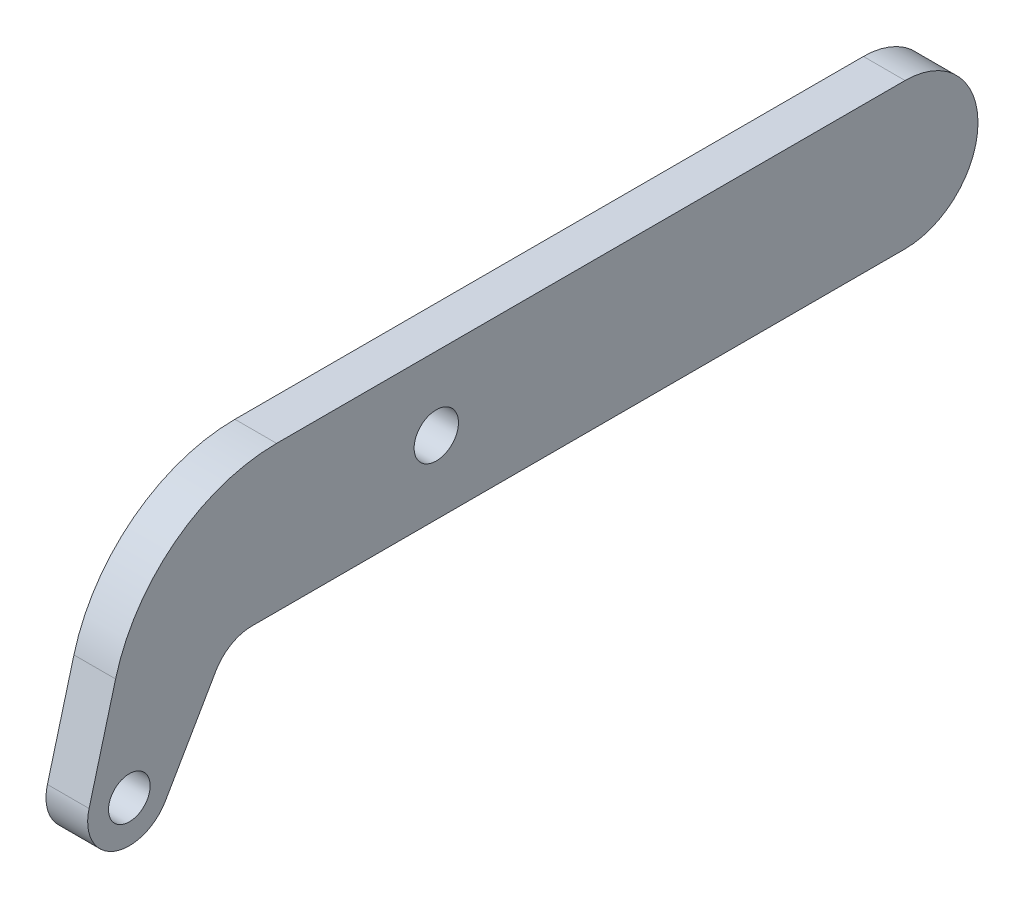
from build123d import *

# Parameters (mm, degrees)
SKETCH1_R           = 3.175
SKETCH1_R_2         = 3.3782
BOSS_EXTRUDE1_DEPTH = 6.35


with BuildPart() as part:
    # Sketch1 → Boss-Extrude1 (new body)
    with BuildSketch(Plane(origin=(0, 0, 0), x_dir=(0, 0, -1), z_dir=(1, 0, 0))):
        with BuildLine():
            Line((3.666174209, 0), (103.1875, 0))
            ThreePointArc((103.1875, 0), (114.3, 11.1125), (103.1875, 22.225))
            Line((103.1875, 22.225), (7.416840435, 22.225))
            ThreePointArc((7.416840435, 22.225), (-8.045699862, 16.976174843), (-17.117675553, 3.399003746))
            Line((-17.117675553, 3.399003746), (-21.157890311, -11.679283006))
            ThreePointArc((-21.157890311, -11.679283006), (-17.45430111, -19.189418974), (-9.525, -16.497783942))
            Line((-9.525, -16.497783942), (-1.833087105, -3.175))
            ThreePointArc((-1.833087105, -3.175), (0.491174209, -0.850738686), (3.666174209, 0))
        make_face()
        with Locations((-15.024261314, -13.322783942)):
            Circle(SKETCH1_R, mode=Mode.SUBTRACT)
        with Locations((31.75, 11.1125)):
            Circle(SKETCH1_R_2, mode=Mode.SUBTRACT)
    extrude(amount=BOSS_EXTRUDE1_DEPTH)


solid = part.part
